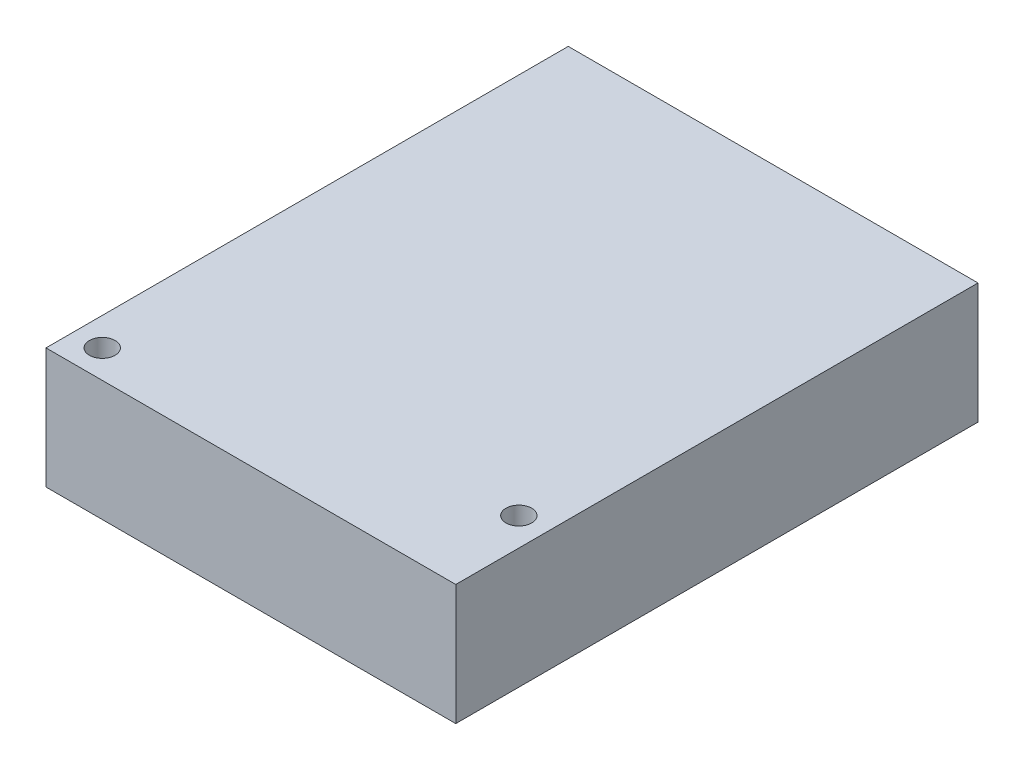
from build123d import *

# Parameters (mm, degrees)
SKETCH1_W           = 51
SKETCH1_H           = 65
SKETCH1_R           = 1.6
BOSS_EXTRUDE1_DEPTH = 15


with BuildPart() as part:
    # Sketch1 → Boss-Extrude1 (new body)
    with BuildSketch(Plane(origin=(0, 0, 0), x_dir=(1, 0, 0), z_dir=(0, 1, 0))):
        Rectangle(SKETCH1_W, SKETCH1_H)
        with Locations((-22, -29)):
            Circle(SKETCH1_R, mode=Mode.SUBTRACT)
        with Locations((22, -21.15)):
            Circle(SKETCH1_R, mode=Mode.SUBTRACT)
    extrude(amount=BOSS_EXTRUDE1_DEPTH)


solid = part.part
